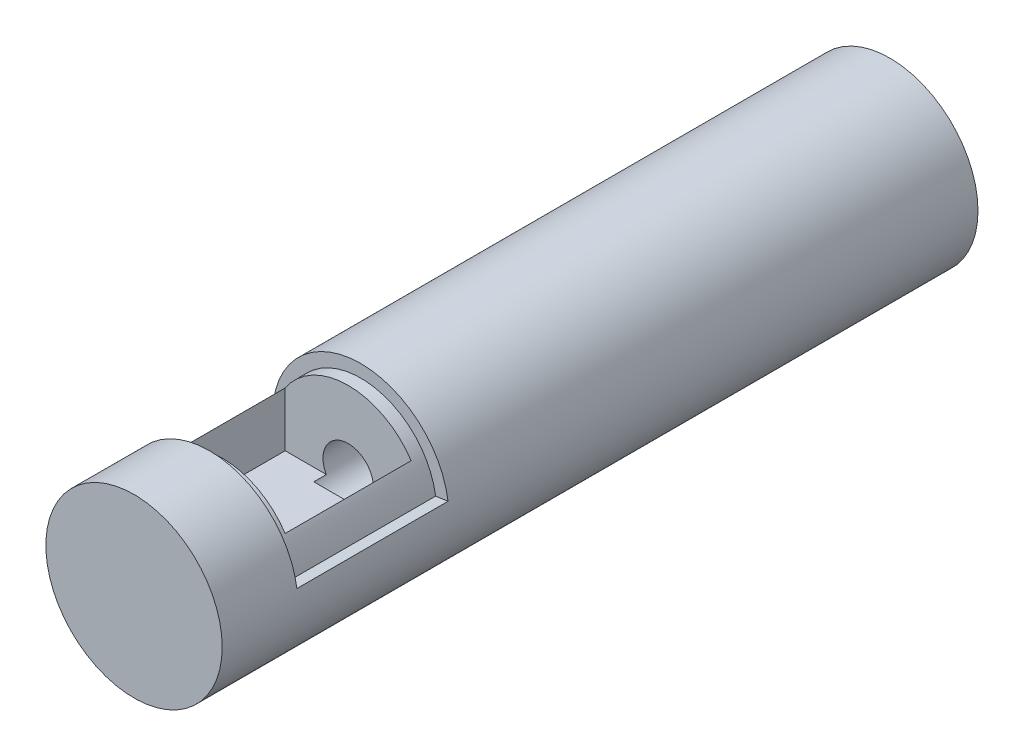
from build123d import *

# Parameters (mm, degrees)
SKETCH2_R           = 22.225
BOSS_EXTRUDE1_DEPTH = 190.5
SKETCH3_R           = 6.35
CUT_EXTRUDE1_DEPTH  = 139.7
WRAP1_SECTION_W     = 3.175
WRAP1_SECTION_H     = 38.1
WRAP1_ANGLE         = 163.70222718
SKETCH6_W           = 31.75
SKETCH6_H           = 31.75
CUT_EXTRUDE2_DEPTH  = 25.4
SKETCH7_R           = 1.190625
CUT_EXTRUDE3_DEPTH  = 31.75
SKETCH8_R           = 6.35
CUT_EXTRUDE4_DEPTH  = 22.225


with BuildPart() as part:
    # Sketch2 → Boss-Extrude1 (new body)
    with BuildSketch(Plane.XY):
        Circle(SKETCH2_R)
    extrude(amount=-BOSS_EXTRUDE1_DEPTH)

    # Sketch3 → Cut-Extrude1 (cut)
    with BuildSketch(Plane(origin=(0, 0, -190.5), x_dir=(-1, 0, 0), z_dir=(0, 0, -1))):
        Circle(SKETCH3_R)
    extrude(amount=-CUT_EXTRUDE1_DEPTH, mode=Mode.SUBTRACT)

    # Wrap1 section (on wrap section) → Wrap1 (revolve, cut)
    with BuildSketch(Plane(origin=(0, 0, 0), x_dir=(0.9899030763721239, 0.14174589725634046, 0), z_dir=(0.14174589725634046, -0.9899030763721239, 0))):
        with Locations((20.6375, -38.1)):
            Rectangle(WRAP1_SECTION_W, WRAP1_SECTION_H)
    revolve(axis=Axis((0, 0, 0), (0, 0, 1)), revolution_arc=WRAP1_ANGLE, mode=Mode.SUBTRACT)

    # Sketch6 → Cut-Extrude2 (cut)
    with BuildSketch(Plane(origin=(0, 22.225, 0), x_dir=(1, 0, 0), z_dir=(0, 1, 0))):
        with Locations((0, 38.1)):
            Rectangle(SKETCH6_W, SKETCH6_H)
    extrude(amount=-CUT_EXTRUDE2_DEPTH, mode=Mode.SUBTRACT)

    # Sketch7 → Cut-Extrude3 (cut)
    with BuildSketch(Plane(origin=(0, 22.225, 0), x_dir=(1, 0, 0), z_dir=(0, 1, 0))):
        with Locations(Location((-8.255, 29.845, 0), (0, 0, 270))):
            Circle(SKETCH7_R)
        with Locations(Location((8.255, 46.355, 0), (0, 0, 270))):
            Circle(SKETCH7_R)
    extrude(amount=-CUT_EXTRUDE3_DEPTH, mode=Mode.SUBTRACT)

    # Sketch8 → Cut-Extrude4 (cut)
    with BuildSketch(Plane(origin=(0, -22.225, 0), x_dir=(-1, 0, 0), z_dir=(0, -1, 0))):
        with Locations(Location((0, 174.625, 0), (0, 0, 90))):
            Circle(SKETCH8_R)
    extrude(amount=-CUT_EXTRUDE4_DEPTH, mode=Mode.SUBTRACT)


solid = part.part
